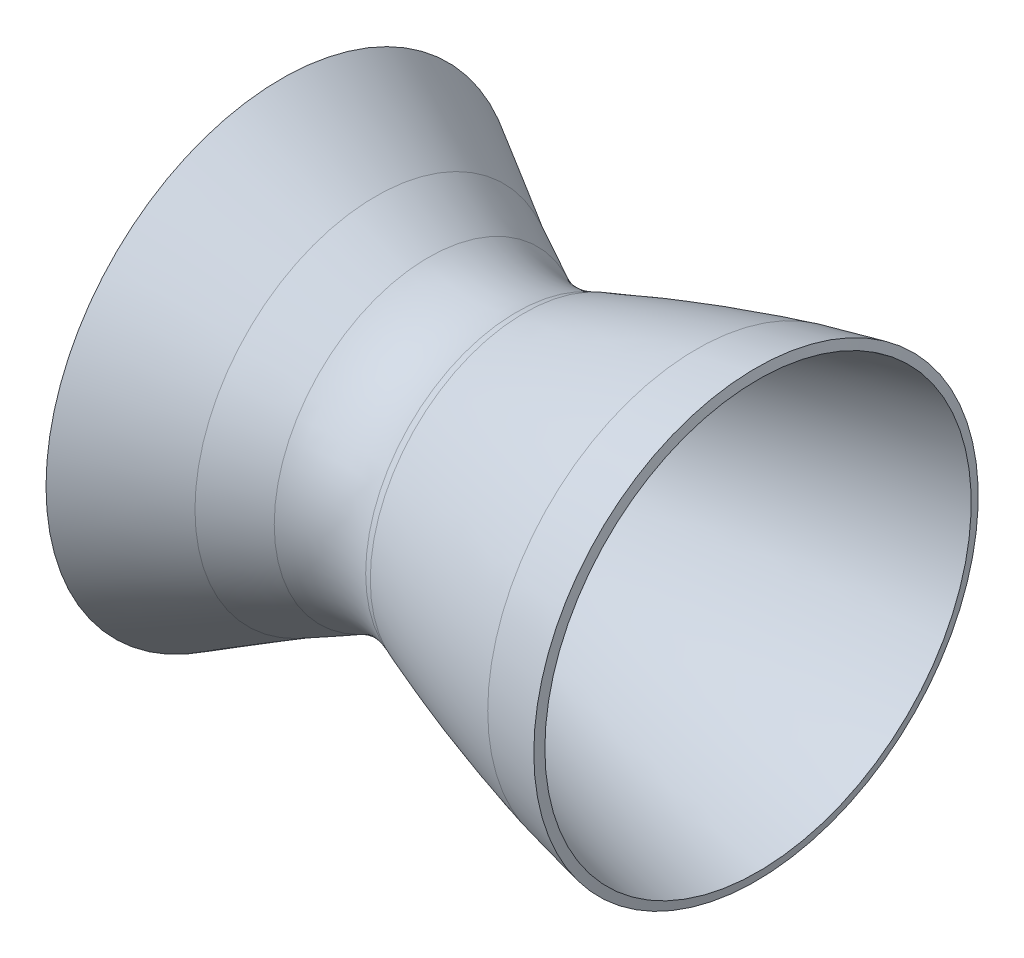
from build123d import *


with BuildPart() as part:
    # Sketch1 → Revolve1 (revolve)
    with BuildSketch(Plane.XY):
        with BuildLine():
            Line((-120.282432541, -5.85308291), (-101.189934492, -16.876139995))
            ThreePointArc((-101.189934492, -16.876139995), (-98.469148075, -18.068527983), (-95.5530911, -18.63516681))
            add(Edge.make_bspline(
                [(-95.5530911, -18.63516681), (-89.800483576, -16.232100699), (-78.169339758, -11.667500611), (-54.691503651, -3.625702949), (-36.76219579, 1.213807703), (-24.683568515, 3.904530155)],
                knots=[0.017508698, 0.017508698, 0.017508698, 0.017508698, 0.263131524, 0.508754349, 1, 1, 1, 1], degree=3))
            Line((-24.683568515, 3.904530155), (-25.185533597, 6.141751328))
            Line((-25.185533597, 6.141751328), (-39.886573133, 2.843280613))
            add(Edge.make_bspline(
                [(-82.526490105, -10.725345919), (-75.535771876, -8.087826575), (-61.392047387, -3.171402737), (-47.094689271, 0.963982134), (-39.886573133, 2.843280613)],
                knots=[0.214165291, 0.214165291, 0.214165291, 0.214165291, 0.507948806, 0.801732321, 0.801732321, 0.801732321, 0.801732321], degree=3))
            Line((-82.526490105, -10.725345919), (-84.466720187, -11.525146883))
            ThreePointArc((-84.466720187, -11.525146883), (-95.45162035, -13.479924278), (-106.252034716, -10.679882178))
            Line((-106.252034716, -10.679882178), (-119.277599097, -4.086975331))
            Line((-119.277599097, -4.086975331), (-142.651647032, 9.408035329))
            Line((-142.651647032, 9.408035329), (-142.651647032, 6.873964468))
            Line((-142.651647032, 6.873964468), (-120.282432541, -5.85308291))
        make_face()
    revolve(axis=Axis((-89.93477047, -48.86116681, 0), (1, 0, 0)))


solid = part.part
